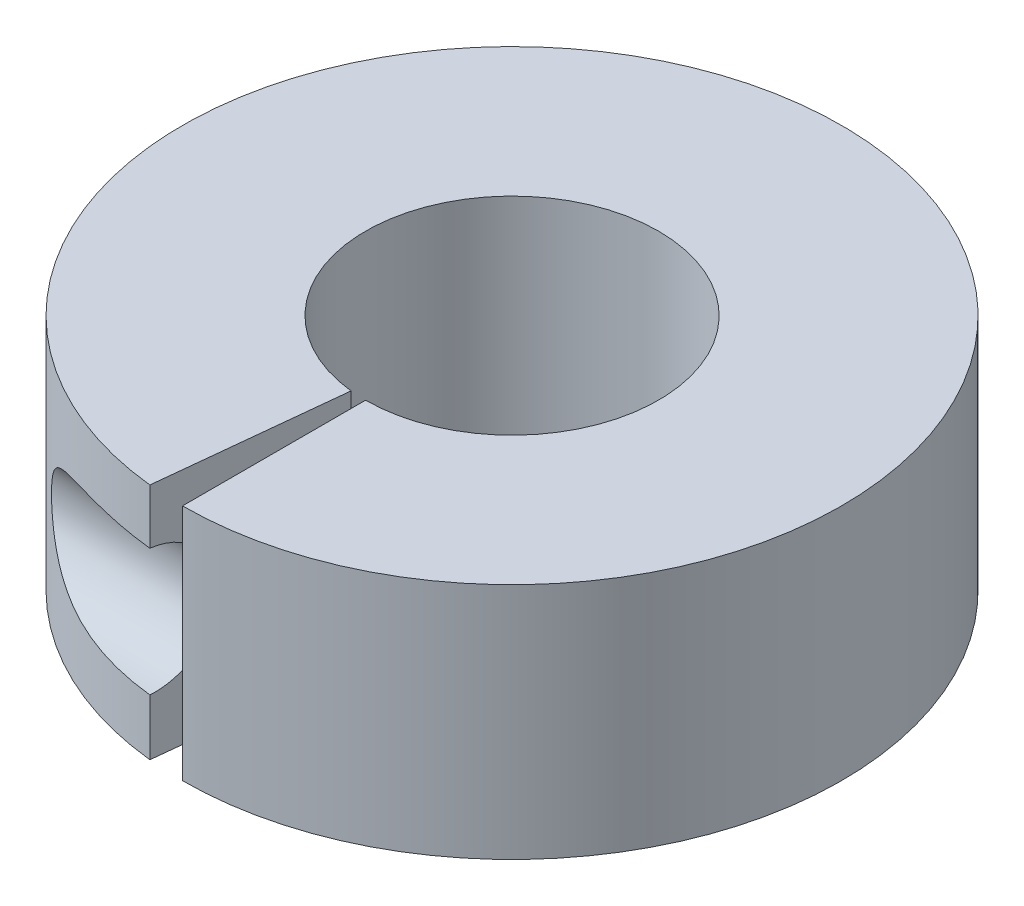
from build123d import *

# Parameters (mm, degrees)
SKETCH1_R           = 14.2875
SKETCH1_R_2         = 6.35
BOSS_EXTRUDE1_DEPTH = 10.31875
CUT_EXTRUDE1_DEPTH  = 10.31875
CUT_EXTRUDE2_DEPTH  = 10.31875


with BuildPart() as part:
    # Sketch1 → Boss-Extrude1 (new body)
    with BuildSketch(Plane(origin=(0, 0, 0), x_dir=(1, 0, 0), z_dir=(0, 1, 0))):
        Circle(SKETCH1_R)
        Circle(SKETCH1_R_2, mode=Mode.SUBTRACT)
    extrude(amount=BOSS_EXTRUDE1_DEPTH)

    # Sketch2 → Cut-Extrude1 (cut)
    with BuildSketch(Plane(origin=(0, 0, 0), x_dir=(0, 0, -1), z_dir=(1, 0, 0))):
        with BuildLine():
            Line((-14.2875, 7.944437688), (-16.071181414, 7.944437688))
            Line((-16.071181414, 7.944437688), (-16.071181414, 2.435187999))
            Line((-16.071181414, 2.435187999), (-14.2875, 2.435187999))
            ThreePointArc((-14.2875, 2.435187999), (-11.532875155, 5.189812844), (-14.2875, 7.944437688))
        make_face()
    extrude(amount=-CUT_EXTRUDE1_DEPTH, mode=Mode.SUBTRACT)

    # Sketch3 → Cut-Extrude2 (cut)
    with BuildSketch(Plane(origin=(0, 10.31875, 0), x_dir=(1, 0, 0), z_dir=(0, 1, 0))):
        with BuildLine():
            Line((0, -6.35), (0, -14.2875))
            ThreePointArc((0, -14.2875), (-0.747749975, -14.267919478), (-1.493450419, -14.20923158))
            Line((-1.493450419, -14.20923158), (-0.663755742, -6.315214036))
            ThreePointArc((-0.663755742, -6.315214036), (-0.332333322, -6.341297546), (0, -6.35))
        make_face()
    extrude(amount=-CUT_EXTRUDE2_DEPTH, mode=Mode.SUBTRACT)


solid = part.part
